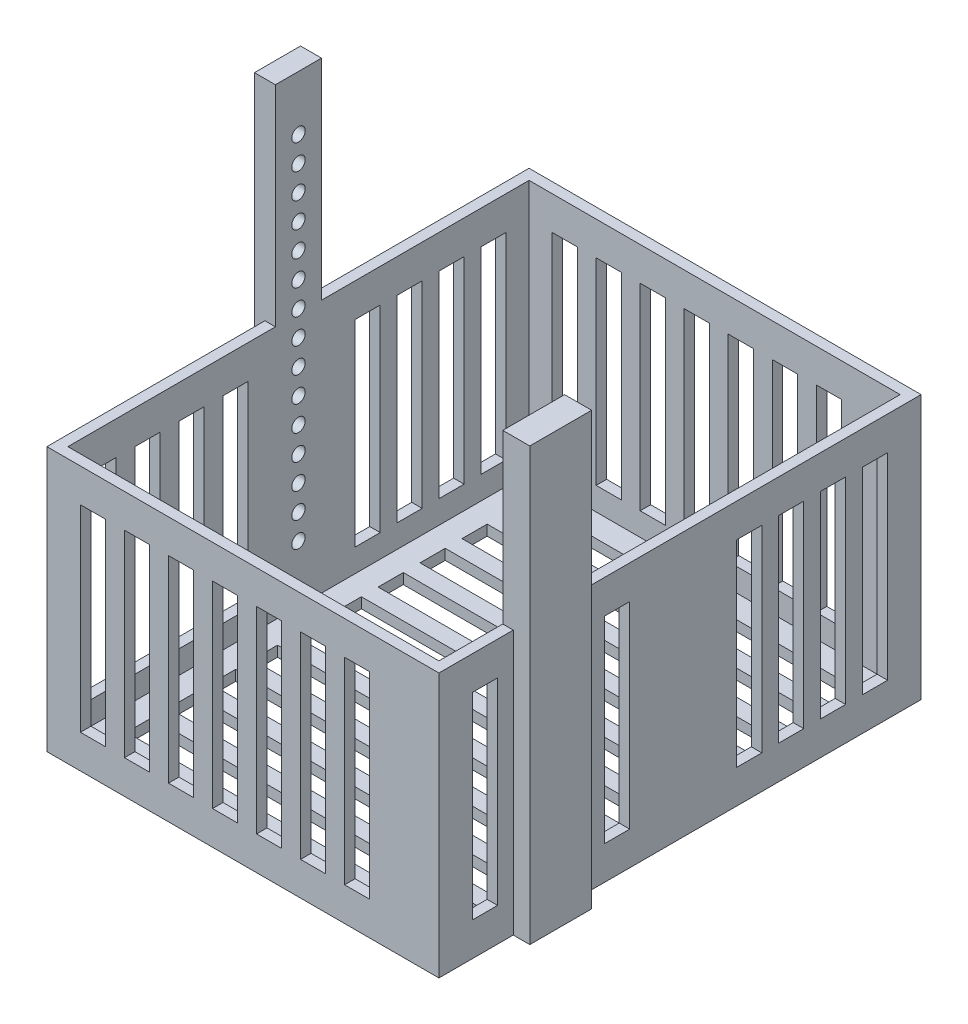
from build123d import *

# Parameters (mm, degrees)
SKETCH1_W           = 93.5
SKETCH1_H           = 115
BOSS_EXTRUDE1_DEPTH = 2.5
SKETCH2_W           = 93.5
SKETCH2_H           = 115
SKETCH2_W_2         = 88.5
SKETCH2_H_2         = 110
BOSS_EXTRUDE2_DEPTH = 60.5
SKETCH3_W           = 5
SKETCH3_H           = 11
BOSS_EXTRUDE3_DEPTH = 63
SKETCH4_W           = 5
SKETCH4_H           = 11
BOSS_EXTRUDE4_DEPTH = 50
SKETCH5_R           = 1.6
CUT_EXTRUDE1_DEPTH  = 5
LPATTERN1_COUNT     = 15
LPATTERN1_PITCH     = 6
SKETCH6_W           = 6
SKETCH6_H           = 47
CUT_EXTRUDE2_DEPTH  = 58.5
LPATTERN2_COUNT     = 7
LPATTERN2_PITCH     = 10.5
CUT_EXTRUDE3_START  = -50.25
SKETCH7_W           = 6
SKETCH7_H           = 47
CUT_EXTRUDE3_DEPTH  = 98
LPATTERN3_COUNT     = 4
LPATTERN3_PITCH     = 10.5
CUT_EXTRUDE4_START  = -50.25
SKETCH8_W           = 6
SKETCH8_H           = 47
CUT_EXTRUDE4_DEPTH  = 98
LPATTERN4_COUNT     = 4
LPATTERN4_PITCH     = 10
CUT_EXTRUDE5_START  = -3.5
SKETCH9_W           = 77.5
SKETCH9_H           = 6
CUT_EXTRUDE5_DEPTH  = 115
LPATTERN5_COUNT     = 10
LPATTERN5_PITCH     = 10
SKETCH11_W          = 6.441149118
SKETCH11_H          = 14.748011809
BOSS_EXTRUDE5_DEPTH = 40
SKETCH12_W          = 3.941149118
SKETCH12_H          = 14.748011809
BOSS_EXTRUDE6_DEPTH = 63


with BuildPart() as part:
    # Sketch1 → Boss-Extrude1 (new body)
    with BuildSketch(Plane(origin=(0, 0, 0), x_dir=(1, 0, 0), z_dir=(0, 1, 0))):
        Rectangle(SKETCH1_W, SKETCH1_H)
    extrude(amount=-BOSS_EXTRUDE1_DEPTH)

    # Sketch2 → Boss-Extrude2 (add)
    with BuildSketch(Plane(origin=(0, 0, 0), x_dir=(1, 0, 0), z_dir=(0, 1, 0))):
        Rectangle(SKETCH2_W, SKETCH2_H)
        Rectangle(SKETCH2_W_2, SKETCH2_H_2, mode=Mode.SUBTRACT)
    extrude(amount=BOSS_EXTRUDE2_DEPTH)

    # Sketch3 → Boss-Extrude3 (add, through all)
    with BuildSketch(Plane.XZ.offset(2.5)):
        with Locations((-46.75, 0)):
            Rectangle(SKETCH3_W, SKETCH3_H)
    extrude(amount=-BOSS_EXTRUDE3_DEPTH)

    # Sketch4 → Boss-Extrude4 (add)
    with BuildSketch(Plane(origin=(0, 60.5, 0), x_dir=(1, 0, 0), z_dir=(0, 1, 0))):
        with Locations((-46.75, 0)):
            Rectangle(SKETCH4_W, SKETCH4_H)
    extrude(amount=BOSS_EXTRUDE4_DEPTH)

    # Sketch5 → Cut-Extrude1 (cut)
    with BuildSketch(Plane.ZY.offset(49.25)):
        with Locations((0, 97.5)):
            Circle(SKETCH5_R)
    cut_extrude1 = extrude(amount=-CUT_EXTRUDE1_DEPTH, mode=Mode.SUBTRACT)

    # LPattern1: Cut-Extrude1 ×15
    with Locations(*[(0, -i * LPATTERN1_PITCH, 0) for i in range(1, LPATTERN1_COUNT)]):
        add(cut_extrude1, mode=Mode.SUBTRACT)

    # Sketch6 → Cut-Extrude2 (cut, symmetric)
    with BuildSketch(Plane.XY):
        with Locations((-35.75, 29)):
            Rectangle(SKETCH6_W, SKETCH6_H)
    cut_extrude2 = extrude(amount=CUT_EXTRUDE2_DEPTH, both=True, mode=Mode.SUBTRACT)

    # LPattern2: Cut-Extrude2 ×7
    with Locations(*[(i * LPATTERN2_PITCH, 0, 0) for i in range(1, LPATTERN2_COUNT)]):
        add(cut_extrude2, mode=Mode.SUBTRACT)

    # Sketch7 → Cut-Extrude3 (cut)
    with BuildSketch(Plane(origin=(0, 0, 0), x_dir=(0, 0, -1), z_dir=(1, 0, 0)).offset(CUT_EXTRUDE3_START)):
        with Locations((-46.5, 29)):
            Rectangle(SKETCH7_W, SKETCH7_H)
    cut_extrude3 = extrude(amount=CUT_EXTRUDE3_DEPTH, mode=Mode.SUBTRACT)

    # LPattern3: Cut-Extrude3 ×4
    with Locations(*[(0, 0, -i * LPATTERN3_PITCH) for i in range(1, LPATTERN3_COUNT)]):
        add(cut_extrude3, mode=Mode.SUBTRACT)

    # Sketch8 → Cut-Extrude4 (cut)
    with BuildSketch(Plane(origin=(0, 0, 0), x_dir=(0, 0, -1), z_dir=(1, 0, 0)).offset(CUT_EXTRUDE4_START)):
        with Locations((46.5, 29)):
            Rectangle(SKETCH8_W, SKETCH8_H)
    cut_extrude4 = extrude(amount=CUT_EXTRUDE4_DEPTH, mode=Mode.SUBTRACT)

    # LPattern4: Cut-Extrude4 ×4
    with Locations(*[(0, 0, i * LPATTERN4_PITCH) for i in range(1, LPATTERN4_COUNT)]):
        add(cut_extrude4, mode=Mode.SUBTRACT)

    # Sketch9 → Cut-Extrude5 (cut)
    with BuildSketch(Plane(origin=(0, 0, 0), x_dir=(1, 0, 0), z_dir=(0, 1, 0)).offset(CUT_EXTRUDE5_START)):
        with Locations((0, 46.5)):
            Rectangle(SKETCH9_W, SKETCH9_H)
    cut_extrude5 = extrude(amount=CUT_EXTRUDE5_DEPTH, mode=Mode.SUBTRACT)

    # LPattern5: Cut-Extrude5 ×10
    with Locations(*[(0, 0, i * LPATTERN5_PITCH) for i in range(1, LPATTERN5_COUNT)]):
        add(cut_extrude5, mode=Mode.SUBTRACT)

    # Sketch11 → Boss-Extrude5 (add)
    with BuildSketch(Plane(origin=(0, 60.5, 0), x_dir=(1, 0, 0), z_dir=(0, 1, 0))):
        with Locations((47.470574559, -32.398557857)):
            Rectangle(SKETCH11_W, SKETCH11_H)
    extrude(amount=BOSS_EXTRUDE5_DEPTH)

    # Sketch12 → Boss-Extrude6 (add, through all)
    with BuildSketch(Plane.XZ.offset(-60.5)):
        with Locations((48.720574559, 32.398557857)):
            Rectangle(SKETCH12_W, SKETCH12_H)
    extrude(amount=BOSS_EXTRUDE6_DEPTH)


solid = part.part
